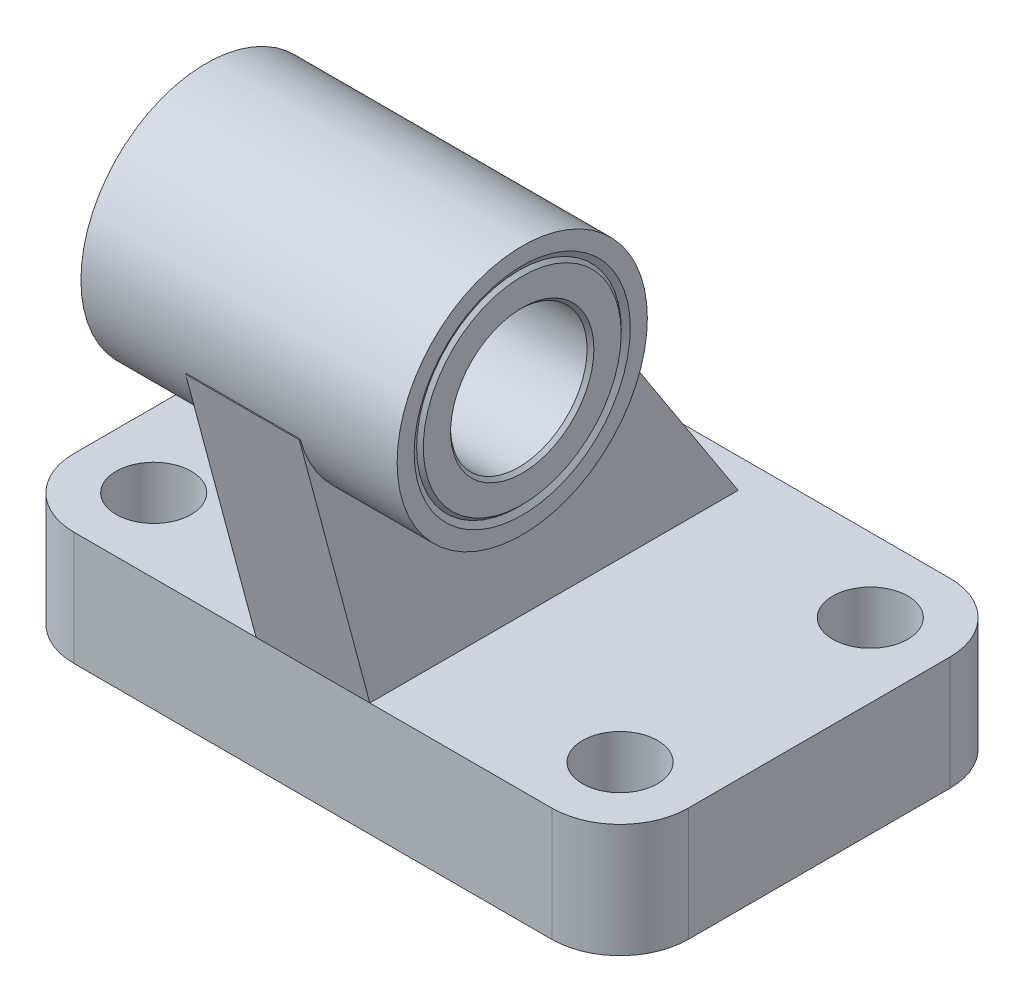
from build123d import *

# Parameters (mm, degrees)
BOSS_EXTRUDE1_DEPTH      = 10
BOSS_EXTRUDE2_DEPTH      = 5
BOSS_EXTRUDE2_DEPTH_BACK = 5
SKETCH3_R                = 11
BOSS_EXTRUDE3_DEPTH      = 13.9
BOSS_EXTRUDE3_DEPTH_BACK = 13.9
SKETCH4_W                = 3.3
SKETCH4_H                = 10
SKETCH5_W                = 3.3
SKETCH5_H                = 10
SKETCH6_W                = 3.3
SKETCH6_H                = 10
SKETCH7_W                = 3.3
SKETCH7_H                = 10


with BuildPart() as part:
    # Sketch1 → Boss-Extrude1 (new body)
    with BuildSketch(Plane(origin=(0, 0, 0), x_dir=(1, 0, 0), z_dir=(0, 1, 0))):
        with BuildLine():
            Line((-21, -17.5), (21, -17.5))
            ThreePointArc((21, -17.5), (25.242640687, -15.742640687), (27, -11.5))
            Line((27, -11.5), (27, 11.5))
            ThreePointArc((27, 11.5), (25.242640687, 15.742640687), (21, 17.5))
            Line((21, 17.5), (-21, 17.5))
            ThreePointArc((-21, 17.5), (-25.242640687, 15.742640687), (-27, 11.5))
            Line((-27, 11.5), (-27, -11.5))
            ThreePointArc((-27, -11.5), (-25.242640687, -15.742640687), (-21, -17.5))
        make_face()
    extrude(amount=BOSS_EXTRUDE1_DEPTH)

    # Sketch2 → Boss-Extrude2 (add, two sides)
    with BuildSketch(Plane(origin=(0, 0, 0), x_dir=(0, 0, -1), z_dir=(1, 0, 0))) as boss_extrude2_sk:
        Polygon((-23.698557159, 33.133330249), (-17.5, 10), (14.884597423, 10), (-3.630389444, 38.510579582), align=None)
    extrude(amount=BOSS_EXTRUDE2_DEPTH)
    extrude(boss_extrude2_sk.sketch, amount=-BOSS_EXTRUDE2_DEPTH_BACK)

    # Sketch3 → Boss-Extrude3 (add, two sides)
    with BuildSketch(Plane(origin=(0, 0, 0), x_dir=(0, 0, -1), z_dir=(1, 0, 0))) as boss_extrude3_sk:
        with Locations((-13, 36)):
            Circle(SKETCH3_R)
    extrude(amount=BOSS_EXTRUDE3_DEPTH)
    extrude(boss_extrude3_sk.sketch, amount=-BOSS_EXTRUDE3_DEPTH_BACK)

    # Sketch4 → Cut-Revolve1 (revolve, cut)
    with BuildSketch(Plane.XY.offset(11)):
        with Locations((-22.15, 5)):
            Rectangle(SKETCH4_W, SKETCH4_H)
    revolve(axis=Axis((-20.5, 10, 11), (0, -1, 0)), mode=Mode.SUBTRACT)

    # Sketch5 → Cut-Revolve2 (revolve, cut)
    with BuildSketch(Plane.XY.offset(11)):
        with Locations((18.85, 5)):
            Rectangle(SKETCH5_W, SKETCH5_H)
    revolve(axis=Axis((20.5, 10, 11), (0, -1, 0)), mode=Mode.SUBTRACT)

    # Sketch6 → Cut-Revolve3 (revolve, cut)
    with BuildSketch(Plane.XY.offset(-11)):
        with Locations((-22.15, 5)):
            Rectangle(SKETCH6_W, SKETCH6_H)
    revolve(axis=Axis((-20.5, 10, -11), (0, -1, 0)), mode=Mode.SUBTRACT)

    # Sketch7 → Cut-Revolve4 (revolve, cut)
    with BuildSketch(Plane.XY.offset(-11)):
        with Locations((18.85, 5)):
            Rectangle(SKETCH7_W, SKETCH7_H)
    revolve(axis=Axis((20.5, 10, -11), (0, -1, 0)), mode=Mode.SUBTRACT)

    # Sketch8 → Cut-Revolve5 (revolve, cut)
    with BuildSketch(Plane.XY.offset(13)):
        Polygon((-13.9, 36), (-13.9, 45.5), (-13.611324865, 45), (13.611324865, 45), (13.9, 45.5), (13.9, 36), align=None)
    revolve(axis=Axis((13.9, 36, 13), (-1, 0, 0)), mode=Mode.SUBTRACT)

    # Sketch9 → Revolve1 (revolve)
    with BuildSketch(Plane.XY.offset(13)):
        Polygon((-13.9, 42.3), (-13.6, 42), (13.6, 42), (13.9, 42.3), (13.9, 44.7), (13.6, 45), (-13.6, 45), (-13.9, 44.7), align=None)
    revolve(axis=Axis((13.9, 36, 13), (-1, 0, 0)))


solid = part.part
